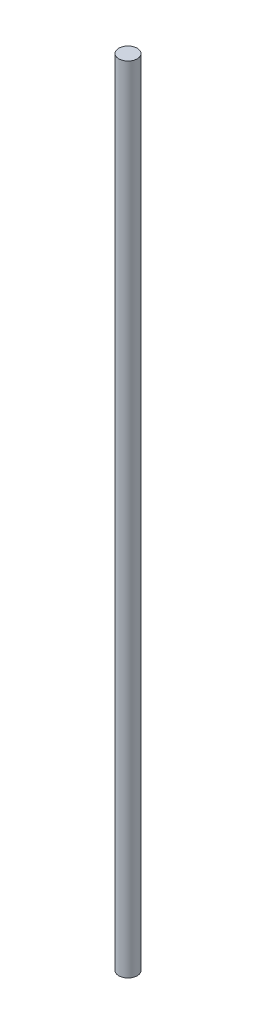
from build123d import *

# Parameters (mm, degrees)
SKETCH1_R           = 4
BOSS_EXTRUDE1_DEPTH = 345


with BuildPart() as part:
    # Sketch1 → Boss-Extrude1 (new body)
    with BuildSketch(Plane(origin=(0, 0, 0), x_dir=(1, 0, 0), z_dir=(0, 1, 0))):
        Circle(SKETCH1_R)
    extrude(amount=BOSS_EXTRUDE1_DEPTH)


solid = part.part
